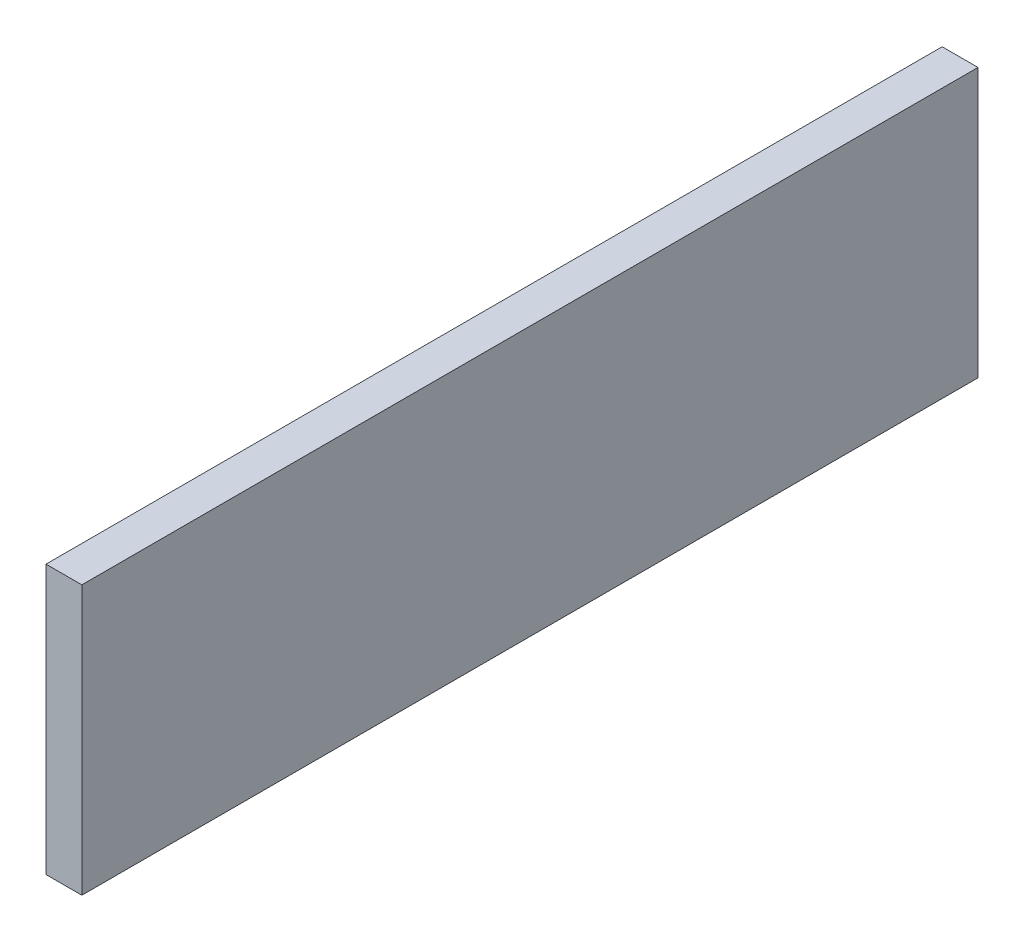
from build123d import *

# Parameters (mm, degrees)
SKETCH1_W           = 63.5
SKETCH1_H           = 19.05
BOSS_EXTRUDE1_DEPTH = 2.54


with BuildPart() as part:
    # Sketch1 → Boss-Extrude1 (new body)
    with BuildSketch(Plane(origin=(0, 0, 0), x_dir=(0, 0, -1), z_dir=(1, 0, 0))):
        with Locations((31.75, -9.525)):
            Rectangle(SKETCH1_W, SKETCH1_H)
    extrude(amount=BOSS_EXTRUDE1_DEPTH)


solid = part.part
